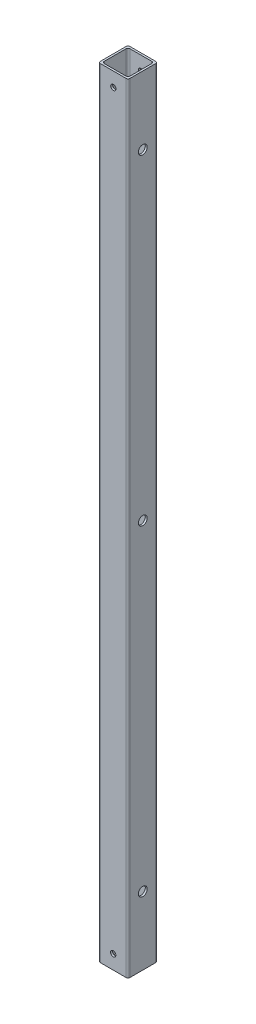
from build123d import *

# Parameters (mm, degrees)
SKETCH1_W                  = 19.304
SKETCH1_H                  = 19.304
SKETCH1_W_2                = 16.764
SKETCH1_H_2                = 16.764
BOSS_EXTRUDE1_DEPTH        = 508
FILLET1_R                  = 1.27
F_1_0_228_DIAMETER_HOLE2_D = 5.7912
F_8_32_TAPPED_HOLE1_D      = 3.4544


with BuildPart() as part:
    # Sketch1 → Boss-Extrude1 (new body)
    with BuildSketch(Plane(origin=(0, 0, 0), x_dir=(1, 0, 0), z_dir=(0, 1, 0))):
        Rectangle(SKETCH1_W, SKETCH1_H)
        Rectangle(SKETCH1_W_2, SKETCH1_H_2, mode=Mode.SUBTRACT)
    extrude(amount=BOSS_EXTRUDE1_DEPTH)

    # Fillet1
    fillet1_edges = [part.edges().sort_by_distance(p)[0] for p in [
        (-8.382, 254, 8.382),
        (8.382, 254, 8.382),
        (8.382, 254, -8.382),
        (-8.382, 254, -8.382),
        (9.652, 254, 9.652),
        (-9.652, 254, 9.652),
        (-9.652, 254, -9.652),
        (9.652, 254, -9.652),
    ]]
    fillet(fillet1_edges, radius=FILLET1_R)

    # #1 (0.228) Diameter Hole2 (through all)
    with Locations(Plane.ZY.offset(9.652)):
        with Locations((0, 463.55), (0, 44.45), (0, 254)):
            Hole(F_1_0_228_DIAMETER_HOLE2_D / 2)

    # #8-32 Tapped Hole1 (through all)
    with Locations(Plane.XY.offset(9.652)):
        with Locations((0, 9.271), (0.103095802, 498.729)):
            Hole(F_8_32_TAPPED_HOLE1_D / 2)


solid = part.part
